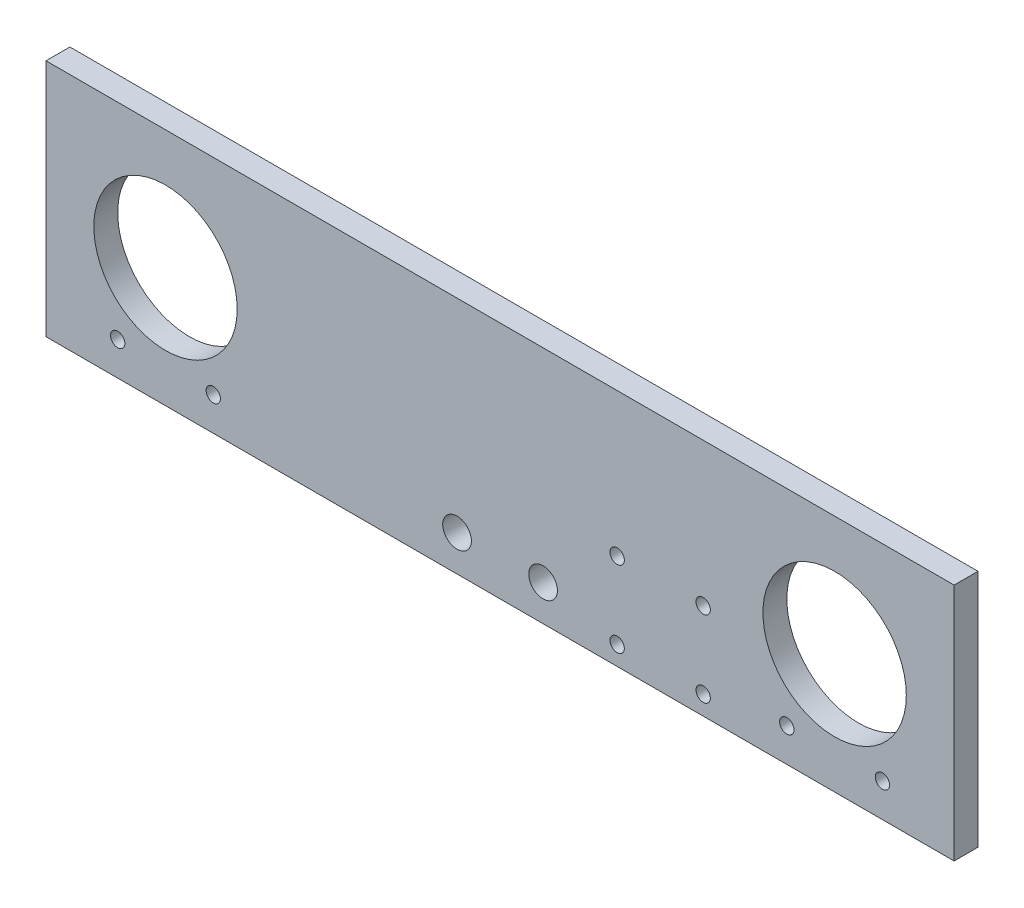
from build123d import *

# Parameters (mm, degrees)
SKETCH1_W           = 190
SKETCH1_H           = 50
SKETCH1_R           = 15
SKETCH1_R_2         = 1.5
SKETCH1_R_3         = 3
BOSS_EXTRUDE1_DEPTH = 5
CUT_EXTRUDE1_START  = -5
SKETCH2_R           = 2.75
CUT_EXTRUDE1_DEPTH  = 1.5


with BuildPart() as part:
    # Sketch1 → Boss-Extrude1 (new body)
    with BuildSketch(Plane.XY):
        with Locations((95, 25)):
            Rectangle(SKETCH1_W, SKETCH1_H)
        with Locations((25, 25)):
            Circle(SKETCH1_R, mode=Mode.SUBTRACT)
        with Locations((165, 25)):
            Circle(SKETCH1_R, mode=Mode.SUBTRACT)
        with Locations((35, 7)):
            Circle(SKETCH1_R_2, mode=Mode.SUBTRACT)
        with Locations((175, 7)):
            Circle(SKETCH1_R_2, mode=Mode.SUBTRACT)
        with Locations((155, 7)):
            Circle(SKETCH1_R_2, mode=Mode.SUBTRACT)
        with Locations((137.5, 4)):
            Circle(SKETCH1_R_2, mode=Mode.SUBTRACT)
        with Locations((86, 7.5)):
            Circle(SKETCH1_R_3, mode=Mode.SUBTRACT)
        with Locations((104, 7.5)):
            Circle(SKETCH1_R_3, mode=Mode.SUBTRACT)
        with Locations((15, 7)):
            Circle(SKETCH1_R_2, mode=Mode.SUBTRACT)
        with Locations((119.5, 4)):
            Circle(SKETCH1_R_2, mode=Mode.SUBTRACT)
        with Locations((119.5, 20)):
            Circle(SKETCH1_R_2, mode=Mode.SUBTRACT)
        with Locations((137.5, 20)):
            Circle(SKETCH1_R_2, mode=Mode.SUBTRACT)
    extrude(amount=BOSS_EXTRUDE1_DEPTH)

    # Sketch2 → Cut-Extrude1 (cut)
    with BuildSketch(Plane.XY.offset(5).offset(CUT_EXTRUDE1_START)):
        with Locations((15, 7)):
            Circle(SKETCH2_R)
        with Locations((35, 7)):
            Circle(SKETCH2_R)
        with Locations((155, 7)):
            Circle(SKETCH2_R)
        with Locations((175, 7)):
            Circle(SKETCH2_R)
    extrude(amount=CUT_EXTRUDE1_DEPTH, mode=Mode.SUBTRACT)


solid = part.part
